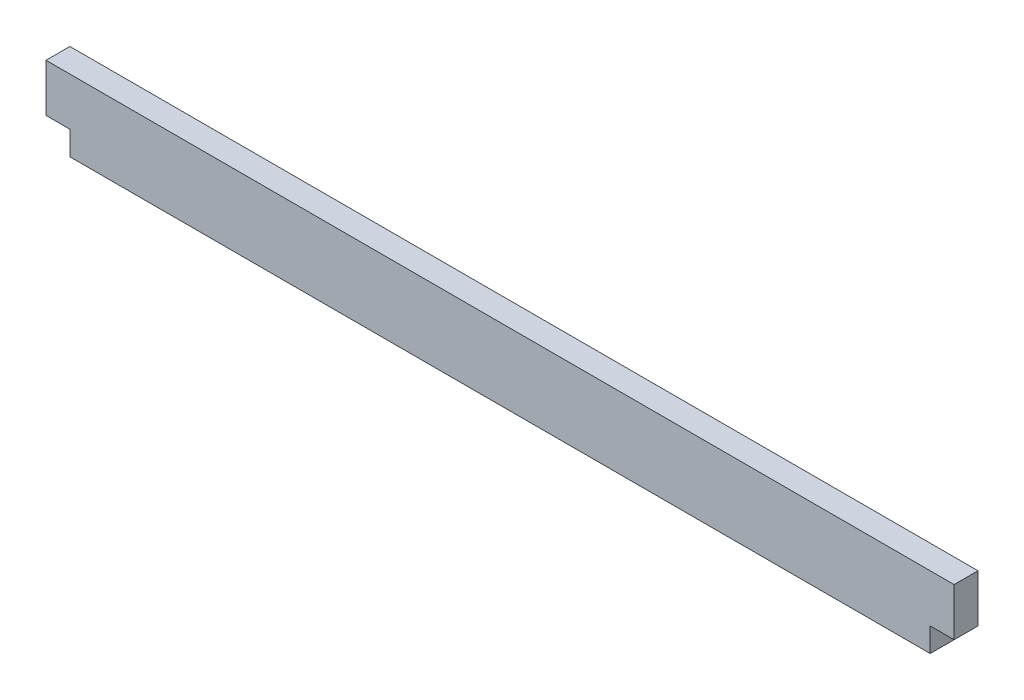
from build123d import *

# Parameters (mm, degrees)
BOSS_EXTRUDE1_DEPTH = 3.175


with BuildPart() as part:
    # Sketch1 → Boss-Extrude1 (new body)
    with BuildSketch(Plane.XY):
        Polygon((88.727168707, 0), (-25.572831293, 0), (-25.572831293, 3.175), (-28.747831293, 3.175), (-28.747831293, 9.525), (91.902168707, 9.525), (91.902168707, 3.175), (88.727168707, 3.175), align=None)
    extrude(amount=BOSS_EXTRUDE1_DEPTH)


solid = part.part
